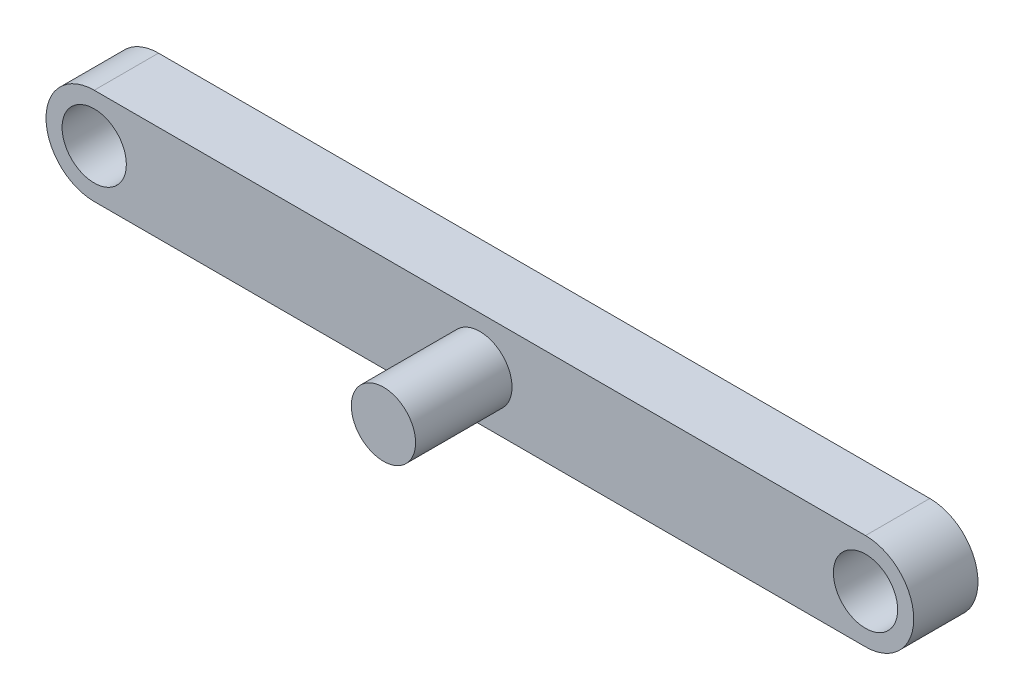
from build123d import *

# Parameters (mm, degrees)
SKETCH1_R           = 2
BOSS_EXTRUDE2_DEPTH = 4
SKETCH1_2_R         = 2
BOSS_EXTRUDE3_DEPTH = 10


with BuildPart() as part:
    # Sketch1 → Boss-Extrude2 (new body)
    with BuildSketch(Plane.XY):
        with BuildLine():
            Line((-24, 3), (24, 3))
            ThreePointArc((24, 3), (27, 0), (24, -3))
            Line((24, -3), (-24, -3))
            ThreePointArc((-24, -3), (-27, 0), (-24, 3))
        make_face()
        with Locations((-24, 0)):
            Circle(SKETCH1_R, mode=Mode.SUBTRACT)
        with Locations((24, 0)):
            Circle(SKETCH1_R, mode=Mode.SUBTRACT)
        Circle(SKETCH1_R, mode=Mode.SUBTRACT)
    extrude(amount=BOSS_EXTRUDE2_DEPTH)

    # Sketch1_2 → Boss-Extrude3 (add)
    with BuildSketch(Plane.XY):
        Circle(SKETCH1_2_R)
    extrude(amount=BOSS_EXTRUDE3_DEPTH)


solid = part.part
